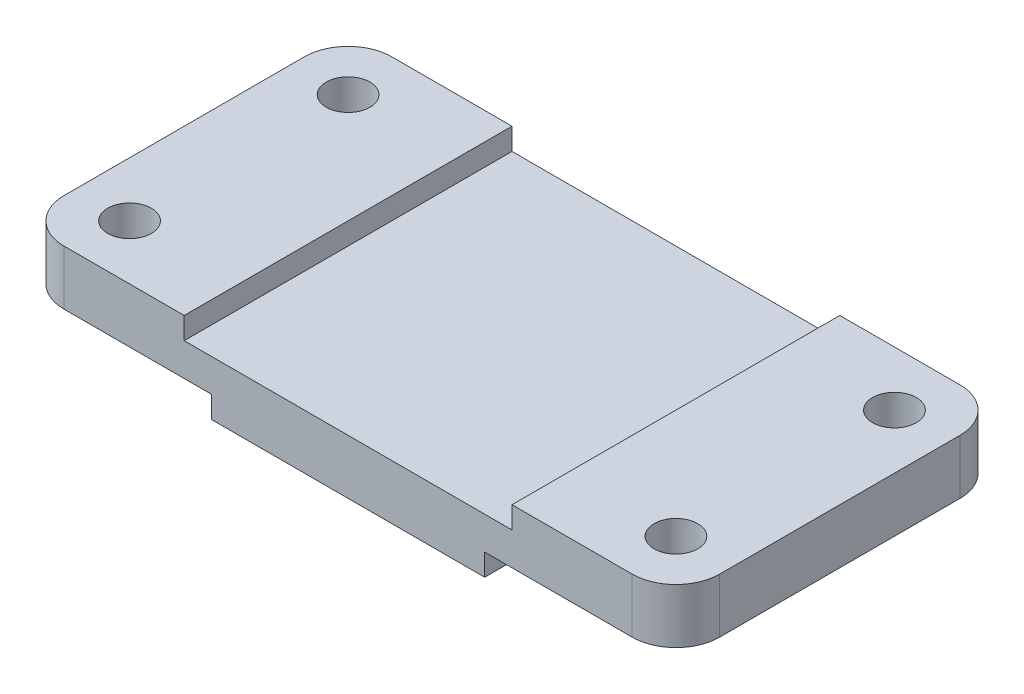
from build123d import *

# Parameters (mm, degrees)
SKETCH1_W               = 76.2
SKETCH1_H               = 38.1
BOSS_EXTRUDE3_DEPTH     = 6.35
SKETCH3_W               = 38.1
SKETCH3_H               = 38.1
CUT_EXTRUDE1_DEPTH      = 2.54
SKETCH4_W               = 31.75
SKETCH4_H               = 38.1
BOSS_EXTRUDE4_DEPTH     = 2.54
SKETCH5_R               = 2.54
CUT_EXTRUDE5_DEPTH      = 6.35
CUT_EXTRUDE5_DEPTH_BACK = 6.35
FILLET1_R               = 5.08


with BuildPart() as part:
    # Sketch1 → Boss-Extrude3 (new body)
    with BuildSketch(Plane(origin=(0, 0, 0), x_dir=(1, 0, 0), z_dir=(0, 1, 0))):
        with Locations((38.1, 19.05)):
            Rectangle(SKETCH1_W, SKETCH1_H)
    extrude(amount=BOSS_EXTRUDE3_DEPTH)

    # Sketch3 → Cut-Extrude1 (cut)
    with BuildSketch(Plane(origin=(0, 6.35, 0), x_dir=(1, 0, 0), z_dir=(0, 1, 0))):
        with Locations((38.1, 19.05)):
            Rectangle(SKETCH3_W, SKETCH3_H)
    extrude(amount=-CUT_EXTRUDE1_DEPTH, mode=Mode.SUBTRACT)

    # Sketch4 → Boss-Extrude4 (add)
    with BuildSketch(Plane.XZ):
        with Locations((38.1, -19.05)):
            Rectangle(SKETCH4_W, SKETCH4_H)
    extrude(amount=BOSS_EXTRUDE4_DEPTH)

    # Sketch5 → Cut-Extrude5 (cut, two sides)
    with BuildSketch(Plane(origin=(0, 3.81, 0), x_dir=(1, 0, 0), z_dir=(0, 1, 0))) as cut_extrude5_sk:
        with Locations((6.35, 31.75)):
            Circle(SKETCH5_R)
        with Locations((6.35, 6.35)):
            Circle(SKETCH5_R)
        with Locations((69.85, 31.75)):
            Circle(SKETCH5_R)
        with Locations((69.85, 6.35)):
            Circle(SKETCH5_R)
    extrude(amount=CUT_EXTRUDE5_DEPTH, mode=Mode.SUBTRACT)
    extrude(cut_extrude5_sk.sketch, amount=-CUT_EXTRUDE5_DEPTH_BACK, mode=Mode.SUBTRACT)

    # Fillet1
    fillet1_edges = [part.edges().sort_by_distance(p)[0] for p in [
        (0, 3.175, -38.1),
        (0, 3.175, 0),
        (76.2, 3.175, 0),
        (76.2, 3.175, -38.1),
    ]]
    fillet(fillet1_edges, radius=FILLET1_R)


solid = part.part
